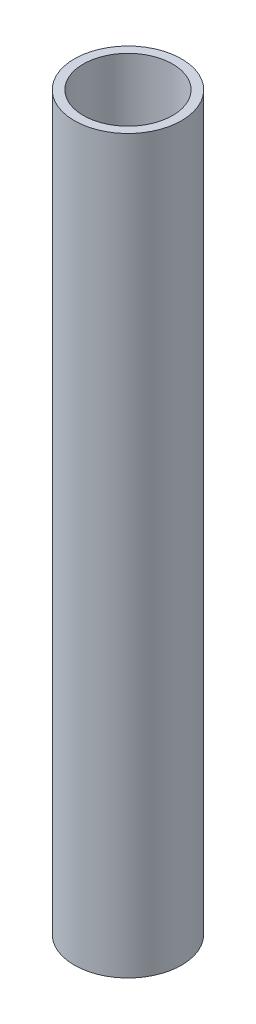
from build123d import *

# Parameters (mm, degrees)
SKETCH1_R           = 9.525
SKETCH1_R_2         = 7.9375
EXTRUDE_THIN1_DEPTH = 130


with BuildPart() as part:
    # Sketch1 → Extrude-Thin1 (new body)
    with BuildSketch(Plane(origin=(0, 0, 0), x_dir=(1, 0, 0), z_dir=(0, 1, 0))):
        Circle(SKETCH1_R)
        Circle(SKETCH1_R_2, mode=Mode.SUBTRACT)
    extrude(amount=EXTRUDE_THIN1_DEPTH)


solid = part.part
